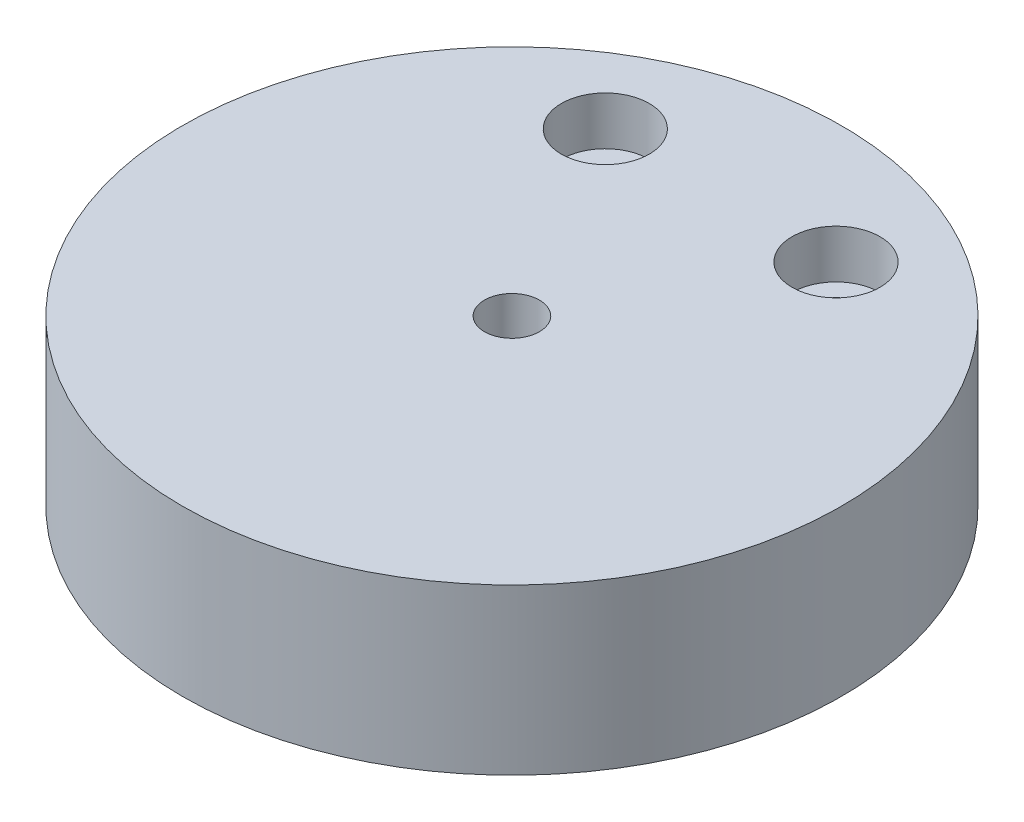
from build123d import *

# Parameters (mm, degrees)
SKETCH1_R                                           = 30
BOSS_EXTRUDE1_DEPTH                                 = 15
SKETCH10_R                                          = 2.5
CUT_EXTRUDE2_DEPTH                                  = 15
CBORE_FOR_M4_HEX_SOCKET_HEAD_CAP_SCREW3_D           = 4.5
CBORE_FOR_M4_HEX_SOCKET_HEAD_CAP_SCREW3_DEPTH       = 15
CBORE_FOR_M4_HEX_SOCKET_HEAD_CAP_SCREW3_CBORE_D     = 8
CBORE_FOR_M4_HEX_SOCKET_HEAD_CAP_SCREW3_CBORE_DEPTH = 4.4


with BuildPart() as part:
    # Sketch1 → Boss-Extrude1 (new body)
    with BuildSketch(Plane(origin=(0, 0, 0), x_dir=(1, 0, 0), z_dir=(0, 1, 0))):
        with Locations((121.722144349, 83.935831041)):
            Circle(SKETCH1_R)
    extrude(amount=BOSS_EXTRUDE1_DEPTH)

    # Sketch10 → Cut-Extrude2 (cut)
    with BuildSketch(Plane(origin=(0, 15, 0), x_dir=(1, 0, 0), z_dir=(0, 1, 0))):
        with Locations((121.722144349, 83.935831041)):
            Circle(SKETCH10_R)
    extrude(amount=-CUT_EXTRUDE2_DEPTH, mode=Mode.SUBTRACT)

    # CBORE for M4 Hex Socket Head Cap Screw3
    with Locations(Plane(origin=(132.222144349, 15, -102.935831041), x_dir=(0, 0, 1), z_dir=(0, 1, 0))):
        with Locations((0, 0), (0, -21)):
            CounterBoreHole(CBORE_FOR_M4_HEX_SOCKET_HEAD_CAP_SCREW3_D / 2, CBORE_FOR_M4_HEX_SOCKET_HEAD_CAP_SCREW3_CBORE_D / 2, CBORE_FOR_M4_HEX_SOCKET_HEAD_CAP_SCREW3_CBORE_DEPTH, depth=CBORE_FOR_M4_HEX_SOCKET_HEAD_CAP_SCREW3_DEPTH)


solid = part.part
